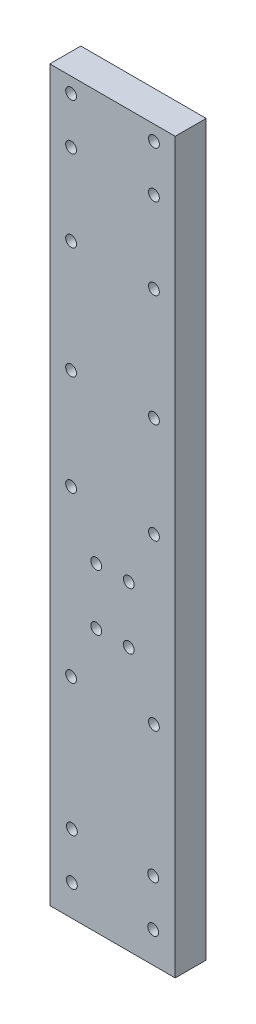
from build123d import *

# Parameters (mm, degrees)
SKETCH3_W           = 16.2
SKETCH3_H           = 94.16
SKETCH3_R           = 0.7
BOSS_EXTRUDE3_DEPTH = 4


with BuildPart() as part:
    # Sketch3 → Boss-Extrude3 (new body)
    with BuildSketch(Plane.XY):
        with Locations((8.1, 46.926448831)):
            Rectangle(SKETCH3_W, SKETCH3_H)
        with Locations((6, 33.846448831)):
            Circle(SKETCH3_R, mode=Mode.SUBTRACT)
        with Locations((10.2, 33.846448831)):
            Circle(SKETCH3_R, mode=Mode.SUBTRACT)
        with Locations((2.75, 86.061448831)):
            Circle(SKETCH3_R, mode=Mode.SUBTRACT)
        with Locations((10.2, 41.166448831)):
            Circle(SKETCH3_R, mode=Mode.SUBTRACT)
        with Locations((13.45, 48.106448831)):
            Circle(SKETCH3_R, mode=Mode.SUBTRACT)
        with Locations((2.75, 92.061448831)):
            Circle(SKETCH3_R, mode=Mode.SUBTRACT)
        with Locations((13.45, 86.061448831)):
            Circle(SKETCH3_R, mode=Mode.SUBTRACT)
        with Locations((2.75, 61.106448831)):
            Circle(SKETCH3_R, mode=Mode.SUBTRACT)
        with Locations((2.85, 9.846448831)):
            Circle(SKETCH3_R, mode=Mode.SUBTRACT)
        with Locations((13.35, 9.846448831)):
            Circle(SKETCH3_R, mode=Mode.SUBTRACT)
        with Locations((13.35, 3.846448831)):
            Circle(SKETCH3_R, mode=Mode.SUBTRACT)
        with Locations((2.85, 3.846448831)):
            Circle(SKETCH3_R, mode=Mode.SUBTRACT)
        with Locations((13.45, 61.106448831)):
            Circle(SKETCH3_R, mode=Mode.SUBTRACT)
        with Locations((2.75, 75.561448831)):
            Circle(SKETCH3_R, mode=Mode.SUBTRACT)
        with Locations((13.45, 26.846448831)):
            Circle(SKETCH3_R, mode=Mode.SUBTRACT)
        with Locations((13.45, 75.561448831)):
            Circle(SKETCH3_R, mode=Mode.SUBTRACT)
        with Locations((13.45, 92.061448831)):
            Circle(SKETCH3_R, mode=Mode.SUBTRACT)
        with Locations((2.75, 26.846448831)):
            Circle(SKETCH3_R, mode=Mode.SUBTRACT)
        with Locations((6, 41.106448831)):
            Circle(SKETCH3_R, mode=Mode.SUBTRACT)
        with Locations((2.75, 48.106448831)):
            Circle(SKETCH3_R, mode=Mode.SUBTRACT)
    extrude(amount=BOSS_EXTRUDE3_DEPTH)


solid = part.part
